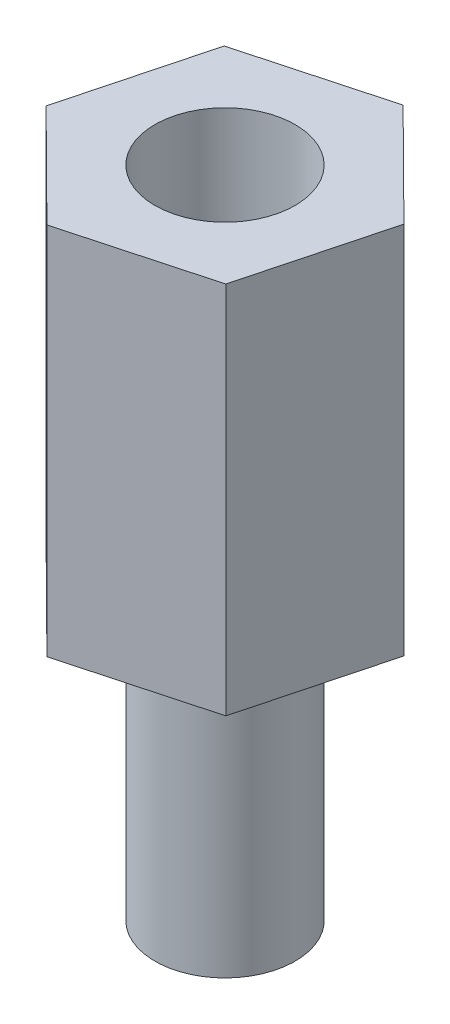
from build123d import *

# Parameters (mm, degrees)
BOSS_EXTRUDE1_DEPTH = 8
SKETCH2_R           = 1.5
CUT_EXTRUDE1_DEPTH  = 6
SKETCH3_R           = 1.5
BOSS_EXTRUDE2_DEPTH = 6


with BuildPart() as part:
    # Sketch1 → Boss-Extrude1 (new body)
    with BuildSketch(Plane(origin=(0, 0, 0), x_dir=(1, 0, 0), z_dir=(0, 1, 0))):
        Polygon((2.213376496, -2.195669484), (3.0081938, 0.819005532), (0.794817304, 3.014675016), (-2.213376496, 2.195669484), (-3.0081938, -0.819005532), (-0.794817304, -3.014675016), align=None)
    extrude(amount=BOSS_EXTRUDE1_DEPTH)

    # Sketch2 → Cut-Extrude1 (cut)
    with BuildSketch(Plane(origin=(0, 8, 0), x_dir=(1, 0, 0), z_dir=(0, 1, 0))):
        Circle(SKETCH2_R)
    extrude(amount=-CUT_EXTRUDE1_DEPTH, mode=Mode.SUBTRACT)

    # Sketch3 → Boss-Extrude2 (add)
    with BuildSketch(Plane.XZ):
        Circle(SKETCH3_R)
    extrude(amount=BOSS_EXTRUDE2_DEPTH)


solid = part.part
